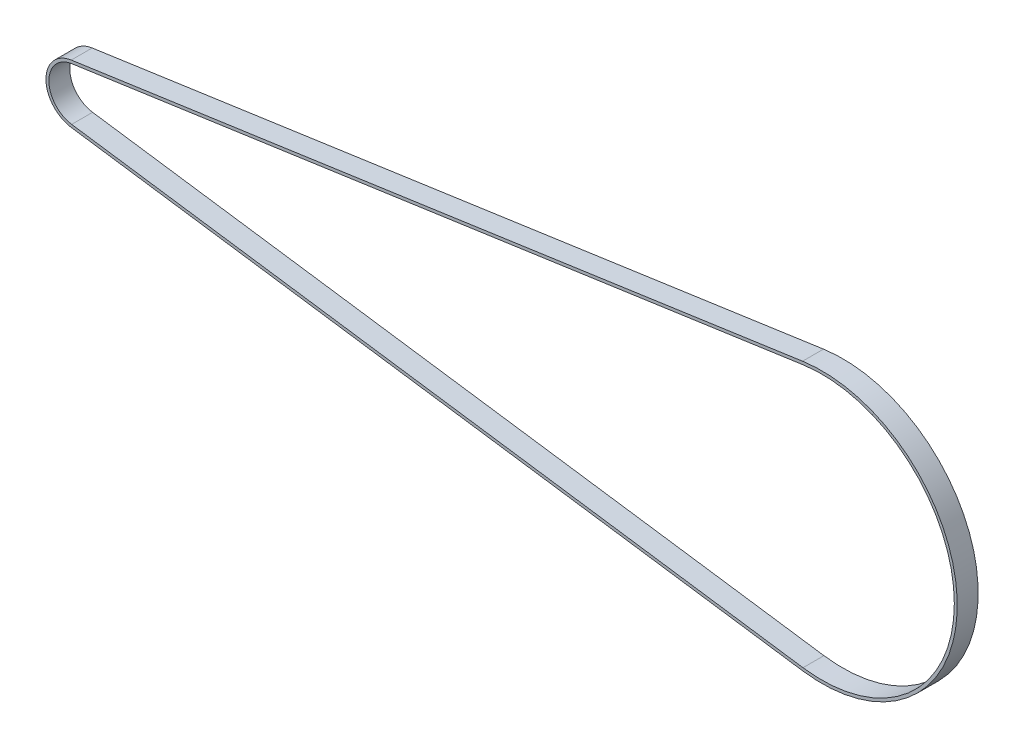
from build123d import *

# Parameters (mm, degrees)
EXTRUDE_THIN1_DEPTH = 14.3002


with BuildPart() as part:
    # Sketch2 → Extrude-Thin1 (new body)
    with BuildSketch(Plane.XY):
        with BuildLine():
            Line((496.863202176, -91.613929858), (-2.861676059, -19.956871777))
            ThreePointArc((-2.861676059, -19.956871777), (-20.161, 0), (-2.861676059, 19.956871777))
            Line((-2.861676059, 19.956871777), (496.863202176, 91.613929858))
            ThreePointArc((496.863202176, 91.613929858), (602.551, 0), (496.863202176, -91.613929858))
        make_face()
        with BuildLine():
            Line((497.147084529, -89.634179669), (-2.577793706, -17.977121589))
            ThreePointArc((-2.577793706, -17.977121589), (-18.161, 0), (-2.577793706, 17.977121589))
            Line((-2.577793706, 17.977121589), (497.147084529, 89.634179669))
            ThreePointArc((497.147084529, 89.634179669), (600.551, 0), (497.147084529, -89.634179669))
        make_face(mode=Mode.SUBTRACT)
    extrude(amount=EXTRUDE_THIN1_DEPTH)


solid = part.part
